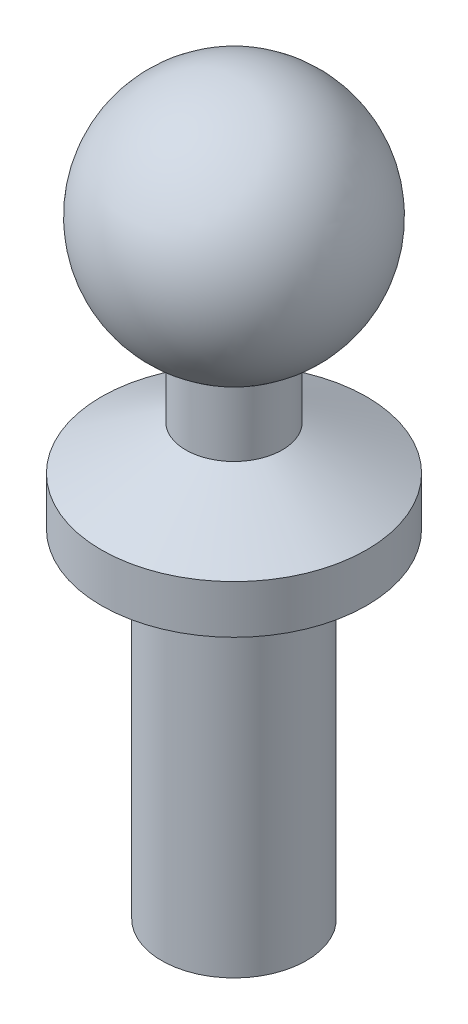
from build123d import *


with BuildPart() as part:
    # Sketch1 → Revolve1 (revolve)
    with BuildSketch(Plane.XY):
        with BuildLine():
            Line((1.5, 0), (1.5, 7))
            Line((1.5, 7), (2.75, 7))
            Line((2.75, 7), (2.75, 8))
            Line((2.75, 8), (1, 8.918712153))
            Line((1, 8.918712153), (1, 10.318712153))
            ThreePointArc((1, 10.318712153), (2.447265782, 13.120774109), (0, 15.11))
            Line((0, 15.11), (0, 0))
            Line((0, 0), (1.5, 0))
        make_face()
    revolve(axis=Axis((0, 0, 0), (0, 1, 0)))


solid = part.part
